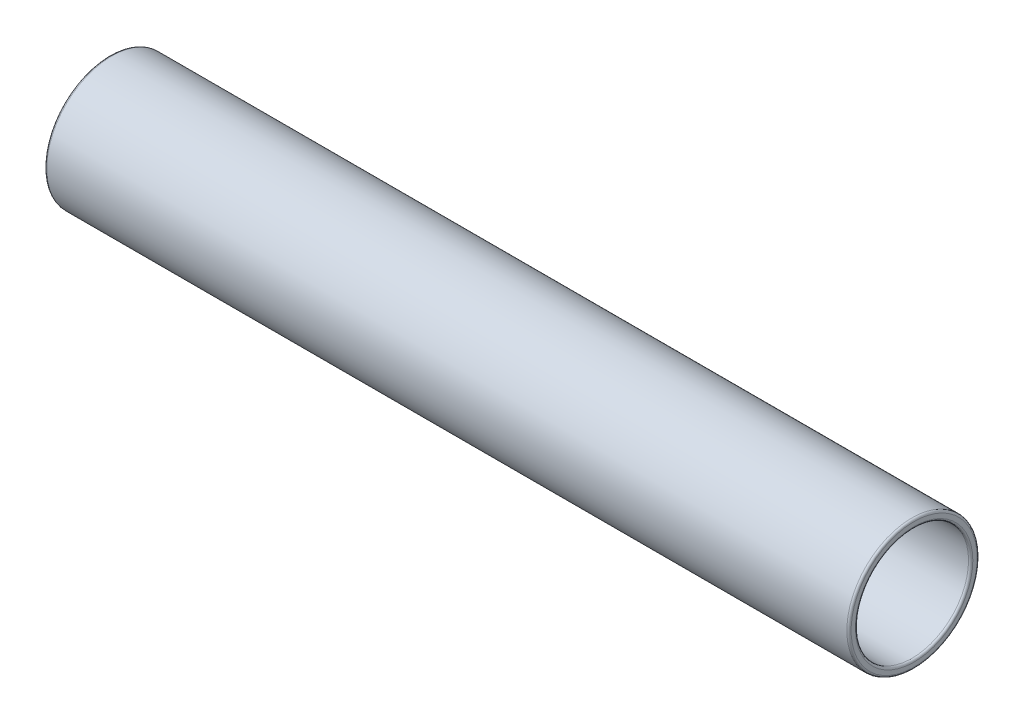
from build123d import *

# Parameters (mm, degrees)
SKETCH1_R           = 60.75
SKETCH1_R_2         = 52.75
BOSS_EXTRUDE1_DEPTH = 750
FILLET1_R           = 2
FILLET2_R           = 2


with BuildPart() as part:
    # Sketch1 → Boss-Extrude1 (new body)
    with BuildSketch(Plane(origin=(0, 0, 0), x_dir=(0, 0, -1), z_dir=(1, 0, 0))):
        Circle(SKETCH1_R)
        Circle(SKETCH1_R_2, mode=Mode.SUBTRACT)
    extrude(amount=BOSS_EXTRUDE1_DEPTH)

    # Fillet1
    fillet1_edges = [part.edges().sort_by_distance(p)[0] for p in [
        (750, 0, 60.75),
        (750, 0, 52.75),
    ]]
    fillet(fillet1_edges, radius=FILLET1_R)

    # Fillet2
    fillet2_edges = [part.edges().sort_by_distance(p)[0] for p in [
        (0, 0, 60.75),
        (0, 0, 52.75),
    ]]
    fillet(fillet2_edges, radius=FILLET2_R)


solid = part.part
